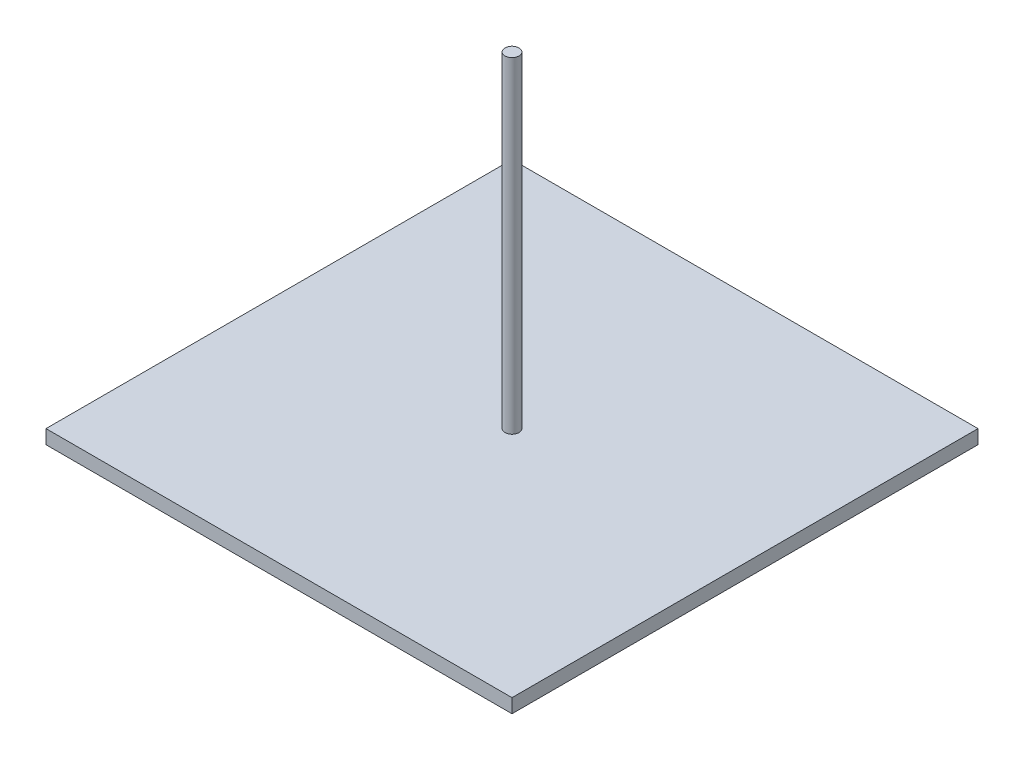
from build123d import *

# Parameters (mm, degrees)
ESTRUSIONE_ESTRUSIONE1_START = 70
SCHIZZO1_W                   = 100
SCHIZZO1_H                   = 100
ESTRUSIONE_ESTRUSIONE1_DEPTH = 3
SCHIZZO2_R                   = 1.5
ESTRUSIONE_ESTRUSIONE2_DEPTH = 70


with BuildPart() as part:
    # Schizzo1 → Estrusione-Estrusione1 (new body)
    with BuildSketch(Plane.XZ.offset(24.14).offset(ESTRUSIONE_ESTRUSIONE1_START)):
        with Locations((-167.062548693, -37.708245302)):
            Rectangle(SCHIZZO1_W, SCHIZZO1_H)
    extrude(amount=ESTRUSIONE_ESTRUSIONE1_DEPTH)

    # Schizzo2 → Estrusione-Estrusione2 (add)
    with BuildSketch(Plane(origin=(0, -94.14, 0), x_dir=(1, 0, 0), z_dir=(0, 1, 0))):
        with Locations((-167.062548693, 37.708245302)):
            Circle(SCHIZZO2_R)
    extrude(amount=ESTRUSIONE_ESTRUSIONE2_DEPTH)


solid = part.part
